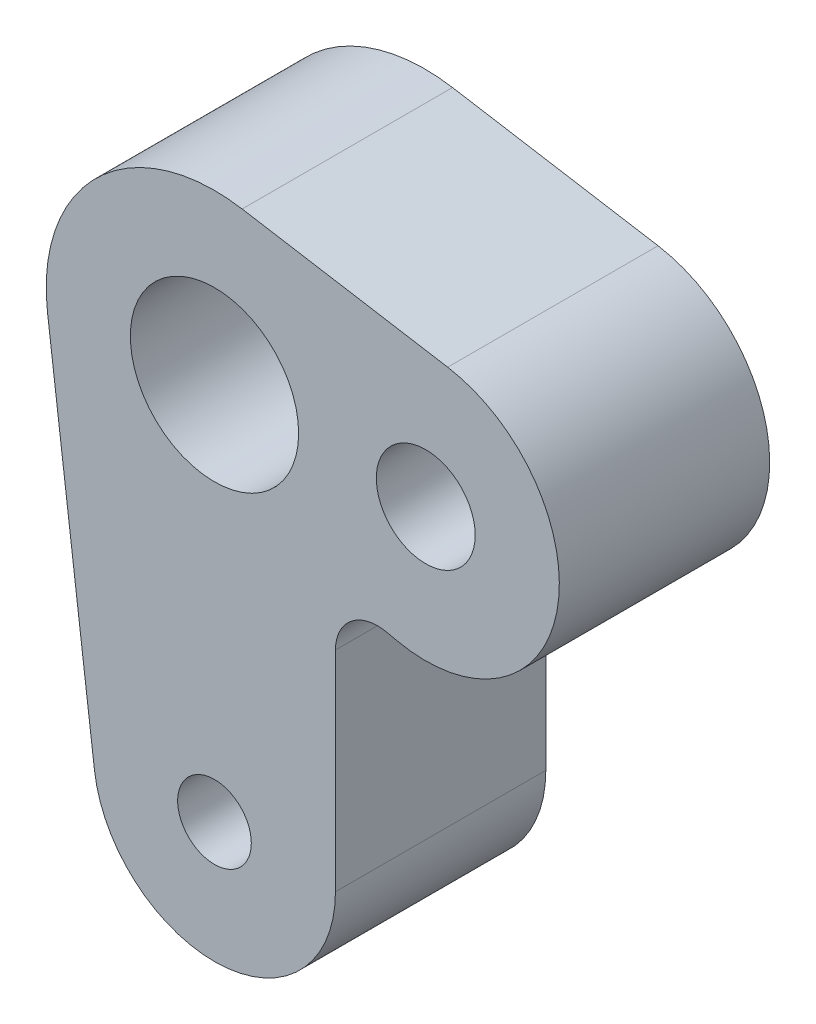
from build123d import *

# Parameters (mm, degrees)
SKETCH1_R           = 2.35
SKETCH1_R_2         = 4
SKETCH1_R_3         = 1.75
BOSS_EXTRUDE1_DEPTH = 10


with BuildPart() as part:
    # Sketch1 → Boss-Extrude1 (new body)
    with BuildSketch(Plane.XY):
        with BuildLine():
            Line((11.085680956, 6.263701723), (1.314433453, 7.891277761))
            ThreePointArc((1.314433453, 7.891277761), (-5.543387307, 5.76808956), (-7.937253933, -1))
            Line((-7.937253933, -1), (-5.704901264, -18.71875))
            ThreePointArc((-5.704901264, -18.71875), (0.360081747, -23.738714241), (5.75, -18))
            Line((5.75, -18), (5.75, -8.04615863))
            ThreePointArc((5.75, -8.04615863), (6.495724286, -6.48834207), (8.176792434, -6.092227153))
            Line((8.176792434, -6.092227153), (8.687283423, -6.20373244))
            ThreePointArc((8.687283423, -6.20373244), (16.278014823, -1.199573574), (11.085680956, 6.263701723))
        make_face()
        with Locations((10.042349402, 0)):
            Circle(SKETCH1_R, mode=Mode.SUBTRACT)
        Circle(SKETCH1_R_2, mode=Mode.SUBTRACT)
        with Locations((0, -18)):
            Circle(SKETCH1_R_3, mode=Mode.SUBTRACT)
    extrude(amount=BOSS_EXTRUDE1_DEPTH)


solid = part.part
